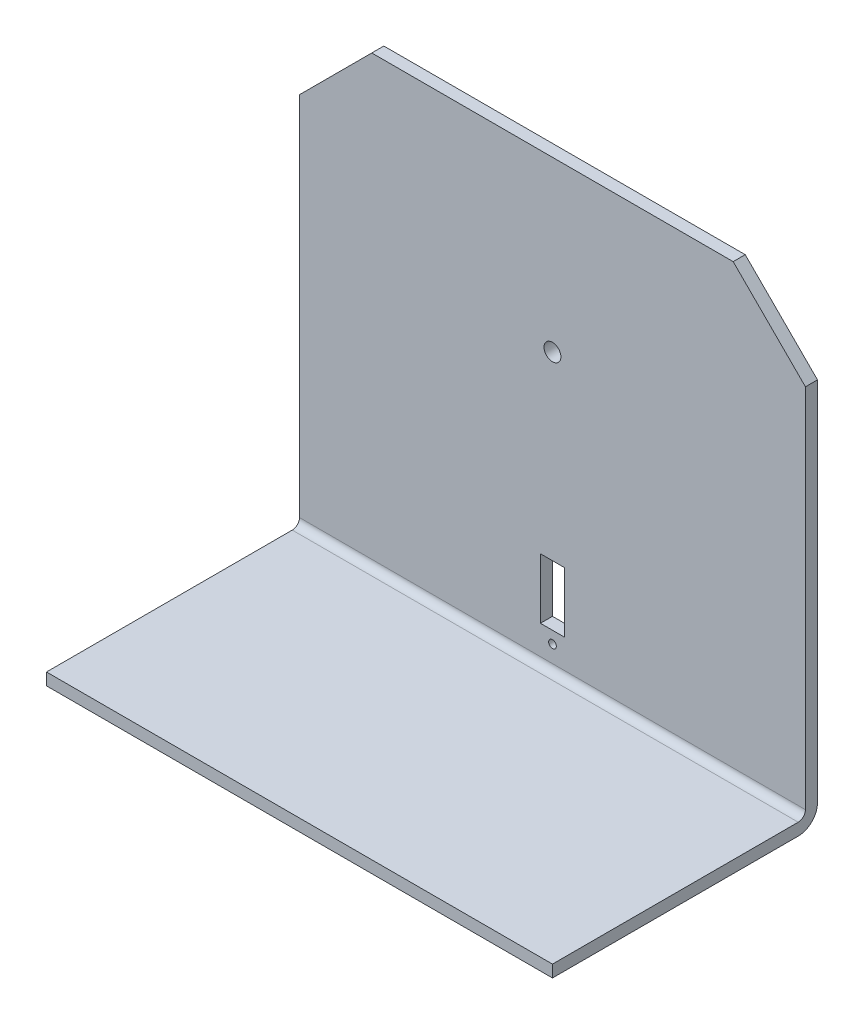
from build123d import *

# Parameters (mm, degrees)
BOSS_EXTRUDE1_DEPTH = 210
FILLET1_R           = 3
FILLET2_R           = 8
SKETCH2_R           = 3.5
SKETCH2_R_2         = 1.6
SKETCH2_W           = 10
SKETCH2_H           = 25
CUT_EXTRUDE1_DEPTH  = 111
CHAMFER1_SIZE       = 30


with BuildPart() as part:
    # Sketch1 → Boss-Extrude1 (new body)
    with BuildSketch(Plane(origin=(0, 0, 0), x_dir=(0, 0, -1), z_dir=(1, 0, 0))):
        Polygon((0, 190), (0, 0), (-110, 0), (-110, 5), (-5, 5), (-5, 190), align=None)
    extrude(amount=BOSS_EXTRUDE1_DEPTH)

    # Fillet1
    fillet1_edges = [part.edges().sort_by_distance(p)[0] for p in [
        (105, 5, 5),
    ]]
    fillet(fillet1_edges, radius=FILLET1_R)

    # Fillet2
    fillet2_edges = [part.edges().sort_by_distance(p)[0] for p in [
        (105, 0, 0),
    ]]
    fillet(fillet2_edges, radius=FILLET2_R)

    # Sketch2 → Cut-Extrude1 (cut, through all)
    with BuildSketch(Plane(origin=(0, 0, 0), x_dir=(-1, 0, 0), z_dir=(0, 0, -1))):
        with Locations((-105, 120)):
            Circle(SKETCH2_R)
        with Locations((-105, 15)):
            Circle(SKETCH2_R_2)
        with Locations((-105, 32.5)):
            Rectangle(SKETCH2_W, SKETCH2_H)
    extrude(amount=-CUT_EXTRUDE1_DEPTH, mode=Mode.SUBTRACT)

    # Chamfer1
    chamfer1_edges = [part.edges().sort_by_distance(p)[0] for p in [
        (210, 190, 2.5),
        (0, 190, 2.5),
    ]]
    chamfer(chamfer1_edges, length=CHAMFER1_SIZE)


solid = part.part
